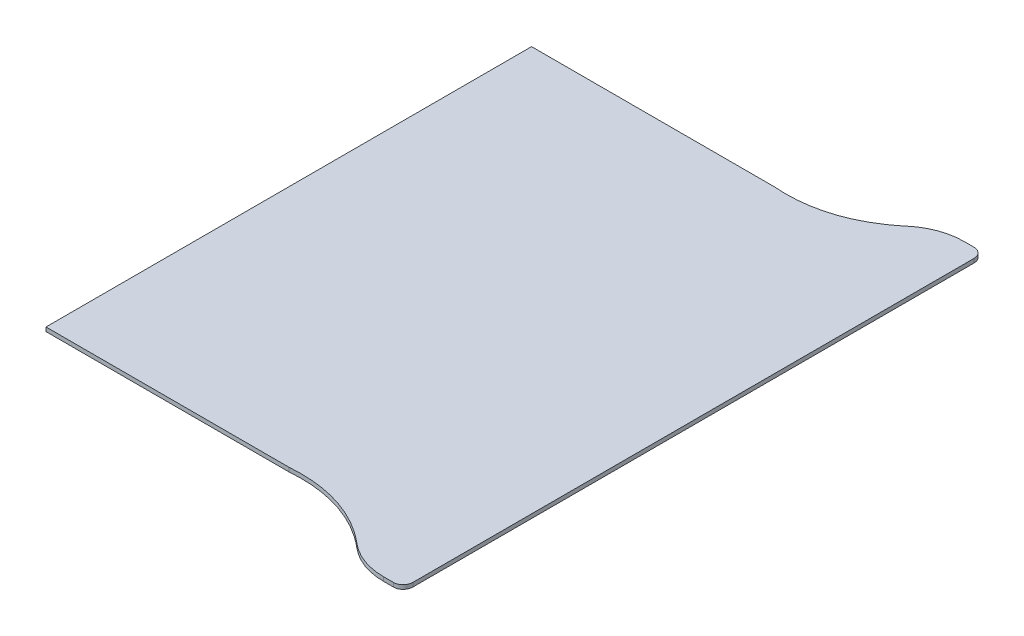
from build123d import *

# Parameters (mm, degrees)
SKETCH_1_W      = 3
SKETCH_1_H      = 6
EXTRUDE_1_DEPTH = 0.05


with BuildPart() as part:
    # 草图1 → 凸台-拉伸1 (new body)
    with BuildSketch(Plane(origin=(0, 0, 0), x_dir=(1, 0, 0), z_dir=(0, 1, 0))):
        Rectangle(SKETCH_1_W, SKETCH_1_H)
        with BuildLine():
            Line((3.5, 0.013586668), (3.5, 3.467136252))
            ThreePointArc((3.5, 3.467136252), (3.464852814, 3.551989066), (3.38, 3.587136252))
            Line((3.38, 3.587136252), (3.256879504, 3.587136252))
            ThreePointArc((3.256879504, 3.587136252), (2.981721672, 3.538327418), (2.740139172, 3.397856671))
            add(Edge.make_bspline(
                [(1.5, 3), (1.961202326, 2.96255509), (2.387230581, 3.099255057), (2.740139172, 3.397856671)],
                knots=[0, 0, 0, 0, 0.839620689, 0.839620689, 0.839620689, 0.839620689], degree=3))
            Line((1.5, 3), (1.5, -3))
            add(Edge.make_bspline(
                [(1.5, -3), (1.961202326, -2.96255509), (2.387230581, -3.099255057), (2.740139172, -3.397856671)],
                knots=[0, 0, 0, 0, 0.839620689, 0.839620689, 0.839620689, 0.839620689], degree=3))
            ThreePointArc((2.740139172, -3.397856671), (2.981721672, -3.538327418), (3.256879504, -3.587136252))
            Line((3.256879504, -3.587136252), (3.38, -3.587136252))
            ThreePointArc((3.38, -3.587136252), (3.464852814, -3.551989066), (3.5, -3.467136252))
            Line((3.5, -3.467136252), (3.5, -0.013586668))
            Line((3.5, -0.013586668), (3.5, 0.013586668))
        make_face()
    extrude(amount=EXTRUDE_1_DEPTH)


solid = part.part
